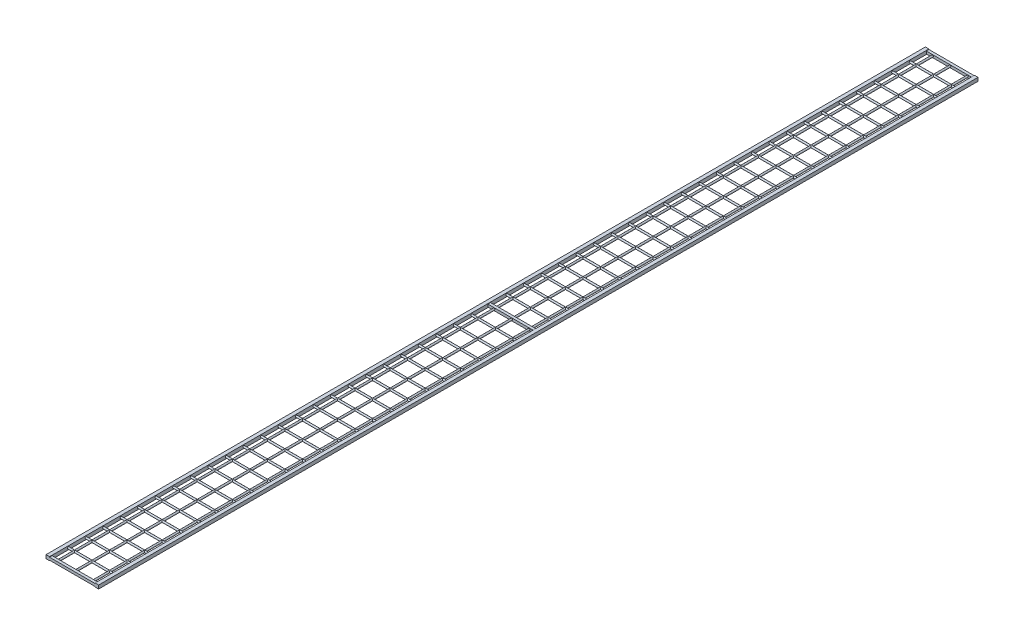
from build123d import *

# Parameters (mm, degrees)
SCHIZZO2_R                        = 2.5
ESTRUSIONE_ESTRUSIONE1_DEPTH      = 2500
ESTRUSIONE_ESTRUSIONE1_2_DEPTH    = 2500
ESTRUSIONE_ESTRUSIONE1_3_DEPTH    = 2500
ESTRUSIONE_ESTRUSIONE1_4_DEPTH    = 2500
ESTRUSIONE_ESTRUSIONE1_5_DEPTH    = 2500
ESTRUSIONE_ESTRUSIONE1_6_DEPTH    = 2500
ESTRUSIONE_ESTRUSIONE1_7_DEPTH    = 2500
ESTRUSIONE_ESTRUSIONE1_8_DEPTH    = 2500
ESTRUSIONE_ESTRUSIONE1_9_DEPTH    = 2500
ESTRUSIONE_ESTRUSIONE1_10_DEPTH   = 2500
ESTRUSIONE_ESTRUSIONE1_11_DEPTH   = 2500
ESTRUSIONE_ESTRUSIONE1_12_DEPTH   = 2500
ESTRUSIONE_ESTRUSIONE1_13_DEPTH   = 2500
ESTRUSIONE_ESTRUSIONE1_14_DEPTH   = 2500
ESTRUSIONE_ESTRUSIONE1_15_DEPTH   = 2500
ESTRUSIONE_ESTRUSIONE1_16_DEPTH   = 2500
ESTRUSIONE_ESTRUSIONE1_17_DEPTH   = 2500
ESTRUSIONE_ESTRUSIONE1_18_DEPTH   = 2500
ESTRUSIONE_ESTRUSIONE1_19_DEPTH   = 2500
SCHIZZO3_R                        = 2.5
ESTRUSIONE_ESTRUSIONE2_DEPTH      = 922.5
ESTRUSIONE_ESTRUSIONE2_DEPTH_BACK = 27.5
SCHIZZO5_W                        = 7.5
SCHIZZO5_H                        = 7.5
ESTRUSIONE_ESTRUSIONE3_DEPTH      = 950
SCHIZZO7_W                        = 10
SCHIZZO7_H                        = 10
ESTRUSIONE_ESTRUSIONE4_DEPTH      = 2507.5
SCHIZZO8_W                        = 928.034228512
SCHIZZO8_H                        = 74.352141311
TAGLIO_ESTRUSIONE1_DEPTH          = 2507.5
SCHIZZO9_W                        = 10
SCHIZZO9_H                        = 10
ESTRUSIONE_ESTRUSIONE5_DEPTH      = 2507.5


with BuildPart() as part:
    # Schizzo2 → Estrusione-Estrusione1 (new body)
    with BuildSketch(Plane.XY):
        Circle(SCHIZZO2_R)
    extrude(amount=ESTRUSIONE_ESTRUSIONE1_DEPTH)

    # Schizzo3 → Estrusione-Estrusione2 (add, two sides)
    with BuildSketch(Plane(origin=(0, 0, 0), x_dir=(0, 0, -1), z_dir=(1, 0, 0))) as estrusione_estrusione2_sk:
        Circle(SCHIZZO3_R)
        with Locations((-50, 0)):
            Circle(SCHIZZO3_R)
        with Locations((-100, 0)):
            Circle(SCHIZZO3_R)
        with Locations((-150, 0)):
            Circle(SCHIZZO3_R)
        with Locations((-200, 0)):
            Circle(SCHIZZO3_R)
        with Locations((-250, 0)):
            Circle(SCHIZZO3_R)
        with Locations((-300, 0)):
            Circle(SCHIZZO3_R)
        with Locations((-350, 0)):
            Circle(SCHIZZO3_R)
        with Locations((-400, 0)):
            Circle(SCHIZZO3_R)
        with Locations((-450, 0)):
            Circle(SCHIZZO3_R)
        with Locations((-500, 0)):
            Circle(SCHIZZO3_R)
        with Locations((-550, 0)):
            Circle(SCHIZZO3_R)
        with Locations((-600, 0)):
            Circle(SCHIZZO3_R)
        with Locations((-650, 0)):
            Circle(SCHIZZO3_R)
        with Locations((-700, 0)):
            Circle(SCHIZZO3_R)
        with Locations((-750, 0)):
            Circle(SCHIZZO3_R)
        with Locations((-800, 0)):
            Circle(SCHIZZO3_R)
        with Locations((-850, 0)):
            Circle(SCHIZZO3_R)
        with Locations((-900, 0)):
            Circle(SCHIZZO3_R)
        with Locations((-950, 0)):
            Circle(SCHIZZO3_R)
        with Locations((-1000, 0)):
            Circle(SCHIZZO3_R)
        with Locations((-1050, 0)):
            Circle(SCHIZZO3_R)
        with Locations((-1100, 0)):
            Circle(SCHIZZO3_R)
        with Locations((-1150, 0)):
            Circle(SCHIZZO3_R)
        with Locations((-1200, 0)):
            Circle(SCHIZZO3_R)
        with Locations((-1250, 0)):
            Circle(SCHIZZO3_R)
        with Locations((-1300, 0)):
            Circle(SCHIZZO3_R)
        with Locations((-1350, 0)):
            Circle(SCHIZZO3_R)
        with Locations((-1400, 0)):
            Circle(SCHIZZO3_R)
        with Locations((-1450, 0)):
            Circle(SCHIZZO3_R)
        with Locations((-1500, 0)):
            Circle(SCHIZZO3_R)
        with Locations((-1550, 0)):
            Circle(SCHIZZO3_R)
        with Locations((-1600, 0)):
            Circle(SCHIZZO3_R)
        with Locations((-1650, 0)):
            Circle(SCHIZZO3_R)
        with Locations((-1700, 0)):
            Circle(SCHIZZO3_R)
        with Locations((-1750, 0)):
            Circle(SCHIZZO3_R)
        with Locations((-1800, 0)):
            Circle(SCHIZZO3_R)
        with Locations((-1850, 0)):
            Circle(SCHIZZO3_R)
        with Locations((-1900, 0)):
            Circle(SCHIZZO3_R)
        with Locations((-1950, 0)):
            Circle(SCHIZZO3_R)
        with Locations((-2000, 0)):
            Circle(SCHIZZO3_R)
        with Locations((-2050, 0)):
            Circle(SCHIZZO3_R)
        with Locations((-2100, 0)):
            Circle(SCHIZZO3_R)
        with Locations((-2150, 0)):
            Circle(SCHIZZO3_R)
        with Locations((-2200, 0)):
            Circle(SCHIZZO3_R)
        with Locations((-2250, 0)):
            Circle(SCHIZZO3_R)
        with Locations((-2300, 0)):
            Circle(SCHIZZO3_R)
        with Locations((-2350, 0)):
            Circle(SCHIZZO3_R)
        with Locations((-2400, 0)):
            Circle(SCHIZZO3_R)
        with Locations((-2450, 0)):
            Circle(SCHIZZO3_R)
        with Locations((-2500, 0)):
            Circle(SCHIZZO3_R)
    extrude(amount=ESTRUSIONE_ESTRUSIONE2_DEPTH)
    extrude(estrusione_estrusione2_sk.sketch, amount=-ESTRUSIONE_ESTRUSIONE2_DEPTH_BACK)



with BuildPart() as body_2:
    # Schizzo2 → Estrusione-Estrusione1 2 (new body)
    with BuildSketch(Plane.XY):
        with Locations((50, 0)):
            Circle(SCHIZZO2_R)
    extrude(amount=ESTRUSIONE_ESTRUSIONE1_2_DEPTH)


with BuildPart() as body_3:
    # Schizzo2 → Estrusione-Estrusione1 3 (new body)
    with BuildSketch(Plane.XY):
        with Locations((100, 0)):
            Circle(SCHIZZO2_R)
    extrude(amount=ESTRUSIONE_ESTRUSIONE1_3_DEPTH)


with BuildPart() as body_4:
    # Schizzo2 → Estrusione-Estrusione1 4 (new body)
    with BuildSketch(Plane.XY):
        with Locations((150, 0)):
            Circle(SCHIZZO2_R)
    extrude(amount=ESTRUSIONE_ESTRUSIONE1_4_DEPTH)


with BuildPart() as body_5:
    # Schizzo2 → Estrusione-Estrusione1 5 (new body)
    with BuildSketch(Plane.XY):
        with Locations((200, 0)):
            Circle(SCHIZZO2_R)
    extrude(amount=ESTRUSIONE_ESTRUSIONE1_5_DEPTH)


with BuildPart() as body_6:
    # Schizzo2 → Estrusione-Estrusione1 6 (new body)
    with BuildSketch(Plane.XY):
        with Locations((250, 0)):
            Circle(SCHIZZO2_R)
    extrude(amount=ESTRUSIONE_ESTRUSIONE1_6_DEPTH)


with BuildPart() as body_7:
    # Schizzo2 → Estrusione-Estrusione1 7 (new body)
    with BuildSketch(Plane.XY):
        with Locations((300, 0)):
            Circle(SCHIZZO2_R)
    extrude(amount=ESTRUSIONE_ESTRUSIONE1_7_DEPTH)


with BuildPart() as body_8:
    # Schizzo2 → Estrusione-Estrusione1 8 (new body)
    with BuildSketch(Plane.XY):
        with Locations((350, 0)):
            Circle(SCHIZZO2_R)
    extrude(amount=ESTRUSIONE_ESTRUSIONE1_8_DEPTH)


with BuildPart() as body_9:
    # Schizzo2 → Estrusione-Estrusione1 9 (new body)
    with BuildSketch(Plane.XY):
        with Locations((400, 0)):
            Circle(SCHIZZO2_R)
    extrude(amount=ESTRUSIONE_ESTRUSIONE1_9_DEPTH)


with BuildPart() as body_10:
    # Schizzo2 → Estrusione-Estrusione1 10 (new body)
    with BuildSketch(Plane.XY):
        with Locations((450, 0)):
            Circle(SCHIZZO2_R)
    extrude(amount=ESTRUSIONE_ESTRUSIONE1_10_DEPTH)


with BuildPart() as body_11:
    # Schizzo2 → Estrusione-Estrusione1 11 (new body)
    with BuildSketch(Plane.XY):
        with Locations((500, 0)):
            Circle(SCHIZZO2_R)
    extrude(amount=ESTRUSIONE_ESTRUSIONE1_11_DEPTH)


with BuildPart() as body_12:
    # Schizzo2 → Estrusione-Estrusione1 12 (new body)
    with BuildSketch(Plane.XY):
        with Locations((550, 0)):
            Circle(SCHIZZO2_R)
    extrude(amount=ESTRUSIONE_ESTRUSIONE1_12_DEPTH)


with BuildPart() as body_13:
    # Schizzo2 → Estrusione-Estrusione1 13 (new body)
    with BuildSketch(Plane.XY):
        with Locations((600, 0)):
            Circle(SCHIZZO2_R)
    extrude(amount=ESTRUSIONE_ESTRUSIONE1_13_DEPTH)


with BuildPart() as body_14:
    # Schizzo2 → Estrusione-Estrusione1 14 (new body)
    with BuildSketch(Plane.XY):
        with Locations((650, 0)):
            Circle(SCHIZZO2_R)
    extrude(amount=ESTRUSIONE_ESTRUSIONE1_14_DEPTH)


with BuildPart() as body_15:
    # Schizzo2 → Estrusione-Estrusione1 15 (new body)
    with BuildSketch(Plane.XY):
        with Locations((700, 0)):
            Circle(SCHIZZO2_R)
    extrude(amount=ESTRUSIONE_ESTRUSIONE1_15_DEPTH)


with BuildPart() as body_16:
    # Schizzo2 → Estrusione-Estrusione1 16 (new body)
    with BuildSketch(Plane.XY):
        with Locations((750, 0)):
            Circle(SCHIZZO2_R)
    extrude(amount=ESTRUSIONE_ESTRUSIONE1_16_DEPTH)


with BuildPart() as body_17:
    # Schizzo2 → Estrusione-Estrusione1 17 (new body)
    with BuildSketch(Plane.XY):
        with Locations((800, 0)):
            Circle(SCHIZZO2_R)
    extrude(amount=ESTRUSIONE_ESTRUSIONE1_17_DEPTH)


with BuildPart() as body_18:
    # Schizzo2 → Estrusione-Estrusione1 18 (new body)
    with BuildSketch(Plane.XY):
        with Locations((850, 0)):
            Circle(SCHIZZO2_R)
    extrude(amount=ESTRUSIONE_ESTRUSIONE1_18_DEPTH)


with BuildPart() as body_19:
    # Schizzo2 → Estrusione-Estrusione1 19 (new body)
    with BuildSketch(Plane.XY):
        with Locations((900, 0)):
            Circle(SCHIZZO2_R)
    extrude(amount=ESTRUSIONE_ESTRUSIONE1_19_DEPTH)


with BuildPart() as part_1:
    add(part.part)

    add(body_2.part)  # Estrusione-Estrusione3 merges body 2

    add(body_3.part)  # Estrusione-Estrusione3 merges body 3

    add(body_4.part)  # Estrusione-Estrusione3 merges body 4

    add(body_5.part)  # Estrusione-Estrusione3 merges body 5

    add(body_6.part)  # Estrusione-Estrusione3 merges body 6

    add(body_7.part)  # Estrusione-Estrusione3 merges body 7

    add(body_8.part)  # Estrusione-Estrusione3 merges body 8

    add(body_9.part)  # Estrusione-Estrusione3 merges body 9

    add(body_10.part)  # Estrusione-Estrusione3 merges body 10

    add(body_11.part)  # Estrusione-Estrusione3 merges body 11

    add(body_12.part)  # Estrusione-Estrusione3 merges body 12

    add(body_13.part)  # Estrusione-Estrusione3 merges body 13

    add(body_14.part)  # Estrusione-Estrusione3 merges body 14

    add(body_15.part)  # Estrusione-Estrusione3 merges body 15

    add(body_16.part)  # Estrusione-Estrusione3 merges body 16

    add(body_17.part)  # Estrusione-Estrusione3 merges body 17

    add(body_18.part)  # Estrusione-Estrusione3 merges body 18

    add(body_19.part)  # Estrusione-Estrusione3 merges body 19
    # Schizzo5 → Estrusione-Estrusione3 (add)
    with BuildSketch(Plane.ZY.offset(27.5)):
        with Locations((1250, 0)):
            Rectangle(SCHIZZO5_W, SCHIZZO5_H)
        Rectangle(SCHIZZO5_W, SCHIZZO5_H)
        with Locations((2500, 0)):
            Rectangle(SCHIZZO5_W, SCHIZZO5_H)
    extrude(amount=-ESTRUSIONE_ESTRUSIONE3_DEPTH)

    # Schizzo7 → Estrusione-Estrusione4 (add)
    with BuildSketch(Plane(origin=(0, 0, -3.75), x_dir=(-1, 0, 0), z_dir=(0, 0, -1))):
        with Locations((22.5, 0)):
            Rectangle(SCHIZZO7_W, SCHIZZO7_H)
        with Locations((-917.5, 0)):
            Rectangle(SCHIZZO7_W, SCHIZZO7_H)
    extrude(amount=-ESTRUSIONE_ESTRUSIONE4_DEPTH)

    # Schizzo8 → Taglio-Estrusione1 (cut)
    with BuildSketch(Plane.XY.offset(2503.75)):
        with Locations((586.517114256, -12.608392488)):
            Rectangle(SCHIZZO8_W, SCHIZZO8_H)
    extrude(amount=-TAGLIO_ESTRUSIONE1_DEPTH, mode=Mode.SUBTRACT)

    # Schizzo9 → Estrusione-Estrusione5 (add)
    with BuildSketch(Plane.XY.offset(2503.75)):
        with Locations((117.5, 0)):
            Rectangle(SCHIZZO9_W, SCHIZZO9_H)
    extrude(amount=-ESTRUSIONE_ESTRUSIONE5_DEPTH)


solid = part_1.part
